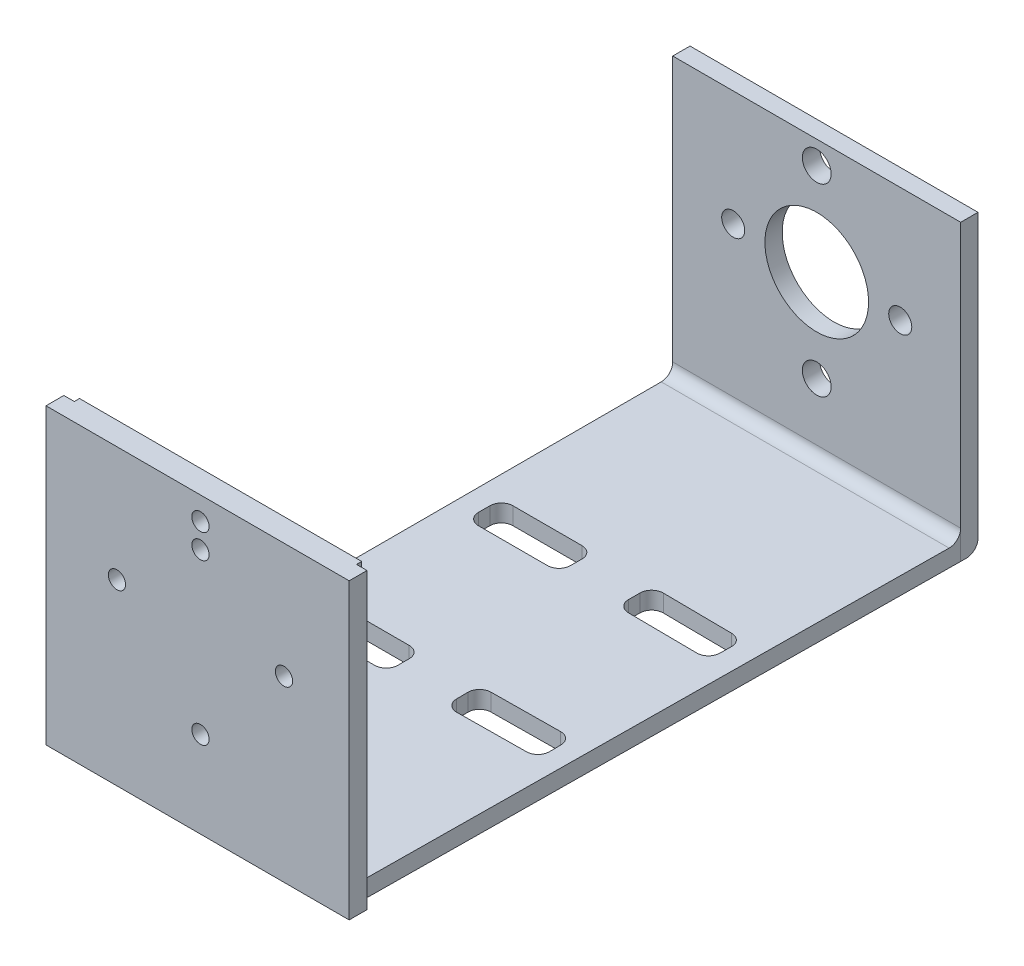
from build123d import *

# Parameters (mm, degrees)
SKETCH_1_W      = 50
SKETCH_1_H      = 51
SKETCH_1_R      = 9
SKETCH_1_R_2    = 2
SKETCH_1_R_3    = 2.5
EXTRUDE_1_DEPTH = 3
SKETCH_2_W      = 16
SKETCH_2_H      = 6
EXTRUDE_2_DEPTH = 3
SKETCH_3_W      = 49
SKETCH_3_H      = 51
SKETCH_3_R      = 1.5
EXTRUDE_3_DEPTH = 4
FILLET_2_R      = 2
FILLET_3_R      = 2
FILLET_4_R      = 2
FILLET_5_R      = 2
FILLET_6_R      = 2
SKETCH_4_W      = 1.818653348
SKETCH_4_H      = 3.1
EXTRUDE_4_DEPTH = 51


with BuildPart() as part:
    # 草图1 → 凸台-拉伸1 (new body)
    with BuildSketch(Plane.XY):
        with Locations((0, -5.5)):
            Rectangle(SKETCH_1_W, SKETCH_1_H)
        Circle(SKETCH_1_R, mode=Mode.SUBTRACT)
        with Locations((14.5, 0)):
            Circle(SKETCH_1_R_2, mode=Mode.SUBTRACT)
        with Locations((-14.5, 0)):
            Circle(SKETCH_1_R_2, mode=Mode.SUBTRACT)
        with Locations((0, 16)):
            Circle(SKETCH_1_R_3, mode=Mode.SUBTRACT)
        with Locations((0, -16)):
            Circle(SKETCH_1_R_3, mode=Mode.SUBTRACT)
    extrude(amount=EXTRUDE_1_DEPTH)

    # 草图2 → 凸台-拉伸2 (add)
    with BuildSketch(Plane.XZ.offset(31)):
        Polygon((-25, 3), (-25, 106), (24, 106), (25, 3), align=None)
        with Locations((-13.25, 39.5)):
            Rectangle(SKETCH_2_W, SKETCH_2_H, mode=Mode.SUBTRACT)
        Polygon((4.866266466, 42.54910809), (4.92451752, 36.549390862), (20.923763461, 36.704727007), (20.865512407, 42.704444235), align=None, mode=Mode.SUBTRACT)
        with Locations((-13.25, 69.5)):
            Rectangle(SKETCH_2_W, SKETCH_2_H, mode=Mode.SUBTRACT)
        Polygon((20.865512407, 66.295555765), (20.923763461, 72.295272993), (4.92451752, 72.450609138), (4.866266466, 66.45089191), align=None, mode=Mode.SUBTRACT)
    extrude(amount=-EXTRUDE_2_DEPTH)

    # 草图3 → 凸台-拉伸3 (add)
    with BuildSketch(Plane.XY.offset(106)):
        with Locations((-0.5, -5.5)):
            Rectangle(SKETCH_3_W, SKETCH_3_H)
        with Locations((-14.5, 0)):
            Circle(SKETCH_3_R, mode=Mode.SUBTRACT)
        with Locations((14.5, 0)):
            Circle(SKETCH_3_R, mode=Mode.SUBTRACT)
        with Locations((0, -16)):
            Circle(SKETCH_3_R, mode=Mode.SUBTRACT)
        with Locations((0, 16)):
            Circle(SKETCH_3_R, mode=Mode.SUBTRACT)
        with Locations((0, 11.75)):
            Circle(SKETCH_3_R, mode=Mode.SUBTRACT)
    extrude(amount=EXTRUDE_3_DEPTH)

    # 圆角2
    fillet_2_edges = [part.edges().sort_by_distance(p)[0] for p in [
        (-5.25, -29.5, 36.5),
    ]]
    fillet(fillet_2_edges, radius=FILLET_2_R)

    # 圆角3
    fillet_3_edges = [part.edges().sort_by_distance(p)[0] for p in [
        (-21.25, -29.5, 36.5),
        (-21.25, -29.5, 42.5),
        (-5.25, -29.5, 42.5),
    ]]
    fillet(fillet_3_edges, radius=FILLET_3_R)

    # 圆角4
    fillet_4_edges = [part.edges().sort_by_distance(p)[0] for p in [
        (20.865512407, -29.5, 42.704444235),
        (20.923763461, -29.5, 36.704727007),
        (4.92451752, -29.5, 36.549390862),
        (4.866266466, -29.5, 42.54910809),
        (-21.25, -29.5, 66.5),
        (-21.25, -29.5, 72.5),
        (-5.25, -29.5, 72.5),
        (-5.25, -29.5, 66.5),
        (4.866266466, -29.5, 66.45089191),
        (4.92451752, -29.5, 72.450609138),
        (20.923763461, -29.5, 72.295272993),
        (20.865512407, -29.5, 66.295555765),
    ]]
    fillet(fillet_4_edges, radius=FILLET_4_R)

    # 圆角5
    fillet_5_edges = [part.edges().sort_by_distance(p)[0] for p in [
        (0, -28, 3),
    ]]
    fillet(fillet_5_edges, radius=FILLET_5_R)

    # 圆角6
    fillet_6_edges = [part.edges().sort_by_distance(p)[0] for p in [
        (0, -31, 0),
    ]]
    fillet(fillet_6_edges, radius=FILLET_6_R)

    # 草图4 → 凸台-拉伸4 (add)
    with BuildSketch(Plane(origin=(0, -31, 0), x_dir=(-1, 0, 0), z_dir=(0, -1, 0))):
        with Locations((-24.909326674, -108.45)):
            Rectangle(SKETCH_4_W, SKETCH_4_H)
        with Locations((25.909326674, -108.45)):
            Rectangle(SKETCH_4_W, SKETCH_4_H)
    extrude(amount=-EXTRUDE_4_DEPTH)


solid = part.part
